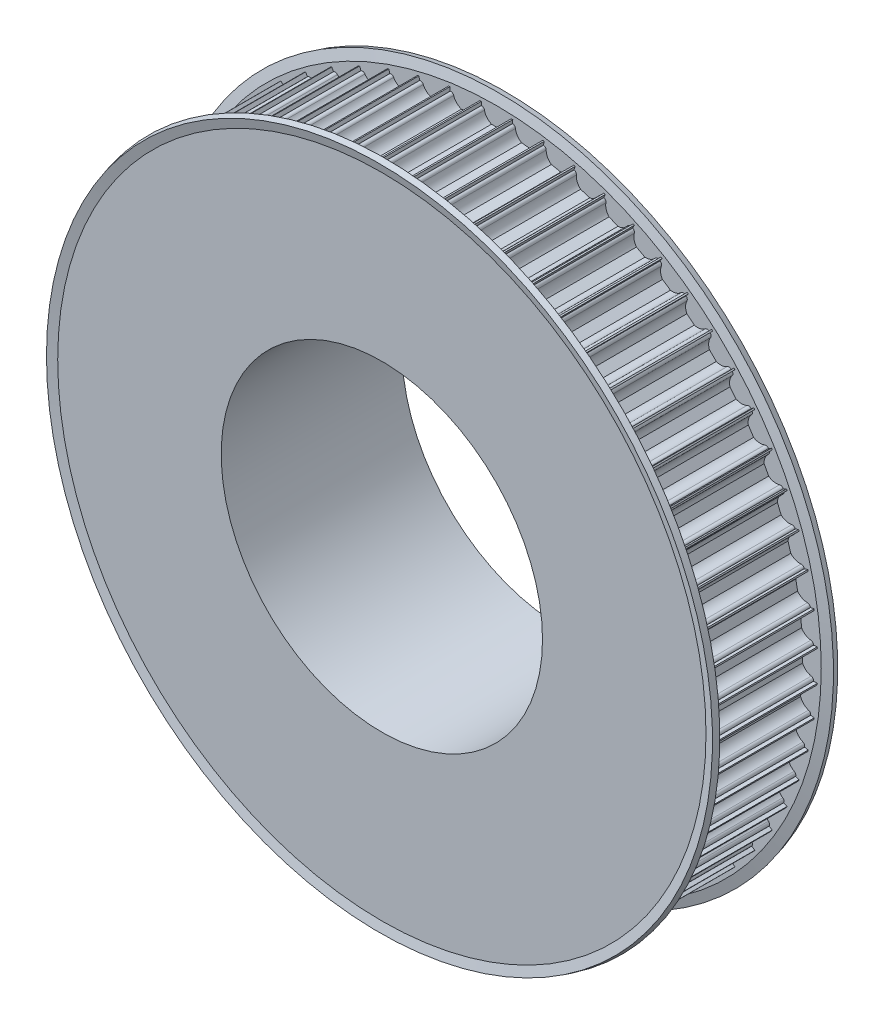
from build123d import *

# Parameters (mm, degrees)
CUT_EXTRUDE1_DEPTH = 30
CIRPATTERN1_COUNT  = 64


with BuildPart() as part:
    # Sketch1 → Revolve1 (revolve)
    with BuildSketch(Plane(origin=(0, 0, 0), x_dir=(0, 0, -1), z_dir=(1, 0, 0))):
        Polygon((0, 40), (0, 80), (30, 80), (30, 55.5), (45, 55.5), (45, 40), align=None)
    revolve(axis=Axis((0, 0, 0), (0, 0, -1)))

    # Sketch2 → Cut-Extrude1 (cut)
    with BuildSketch(Plane.XY):
        with BuildLine():
            Line((-3.674234614, 79), (-3.75, 79))
            Line((-3.75, 79), (-3.75, 81))
            Line((-3.75, 81), (3.75, 81))
            Line((3.75, 81), (3.75, 79))
            Line((3.75, 79), (3.674234614, 79))
            ThreePointArc((3.674234614, 79), (3.199892965, 78.830947502), (2.939387691, 78.4))
            ThreePointArc((2.939387691, 78.4), (2.331759211, 77.112435701), (1.198957881, 76.25))
            Line((1.198957881, 76.25), (-1.198957881, 76.25))
            ThreePointArc((-1.198957881, 76.25), (-2.331759211, 77.112435701), (-2.939387691, 78.4))
            ThreePointArc((-2.939387691, 78.4), (-3.199892965, 78.830947502), (-3.674234614, 79))
        make_face()
    cut_extrude1 = extrude(amount=-CUT_EXTRUDE1_DEPTH, mode=Mode.SUBTRACT)

    # CirPattern1: Cut-Extrude1 ×64 about axis
    cirpattern1_axis = Axis((0, 0, 0), (0, 0, 1))
    for i in range(1, CIRPATTERN1_COUNT):
        add(cut_extrude1.rotate(cirpattern1_axis, i * 360 / CIRPATTERN1_COUNT), mode=Mode.SUBTRACT)

    # Sketch3 → Revolve2 (revolve)
    with BuildSketch(Plane(origin=(0, 0, 0), x_dir=(0, 0, -1), z_dir=(1, 0, 0))):
        Polygon((30, 55.5), (30, 80.702521254), (30.591966801, 82.911771432), (29.143078062, 83.3), (28.5, 80.9), (28.5, 55.5), align=None)
        Polygon((1.5, 80.9), (1.5, 55.5), (0, 55.5), (0, 80.702521254), (-0.591966801, 82.911771432), (0.856921938, 83.3), align=None)
    revolve(axis=Axis((0, 0, 0), (0, 0, 1)))


solid = part.part
